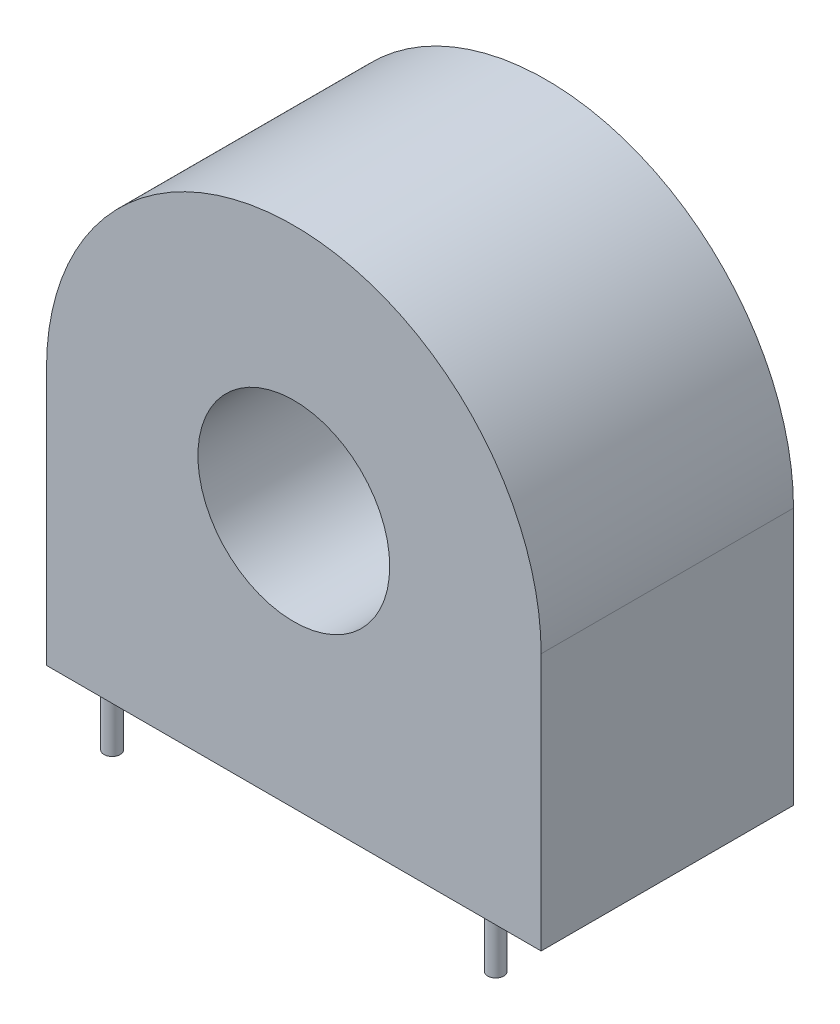
from build123d import *

# Parameters (mm, degrees)
SKETCH_1_R      = 4.75
EXTRUDE_1_DEPTH = 12.5
SKETCH_2_R      = 0.4
EXTRUDE_2_DEPTH = 2.5


with BuildPart() as part:
    # Эскиз1 → Бобышка-Вытянуть1 (new body)
    with BuildSketch(Plane.XY):
        with BuildLine():
            Line((12.25, -6.375), (-12.25, -6.375))
            Line((-12.25, -6.375), (-12.25, 6.375))
            ThreePointArc((-12.25, 6.375), (0, 18.625), (12.25, 6.375))
            Line((12.25, 6.375), (12.25, -6.375))
        make_face()
        with Locations((0, 6.375)):
            Circle(SKETCH_1_R, mode=Mode.SUBTRACT)
    extrude(amount=EXTRUDE_1_DEPTH)

    # Эскиз2 → Бобышка-Вытянуть2 (add)
    with BuildSketch(Plane.XZ.offset(6.375)):
        with Locations((7.4, 0.5)):
            Circle(SKETCH_2_R)
        with Locations((-7.4, 0.5)):
            Circle(SKETCH_2_R)
        with Locations((9.5, 12)):
            Circle(SKETCH_2_R)
        with Locations((-9.5, 12)):
            Circle(SKETCH_2_R)
    extrude(amount=EXTRUDE_2_DEPTH)


solid = part.part
